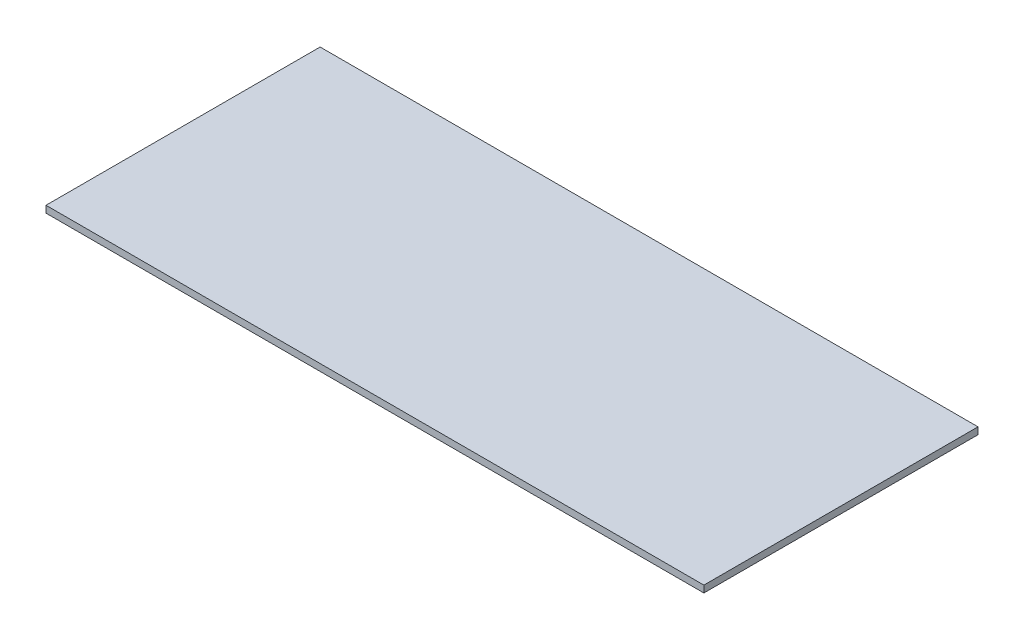
from build123d import *

# Parameters (mm, degrees)
SKETCH1_W           = 288
SKETCH1_H           = 120
BOSS_EXTRUDE1_DEPTH = 3


with BuildPart() as part:
    # Sketch1 → Boss-Extrude1 (new body)
    with BuildSketch(Plane(origin=(0, 0, 0), x_dir=(1, 0, 0), z_dir=(0, 1, 0))):
        Rectangle(SKETCH1_W, SKETCH1_H)
    extrude(amount=BOSS_EXTRUDE1_DEPTH)


solid = part.part
